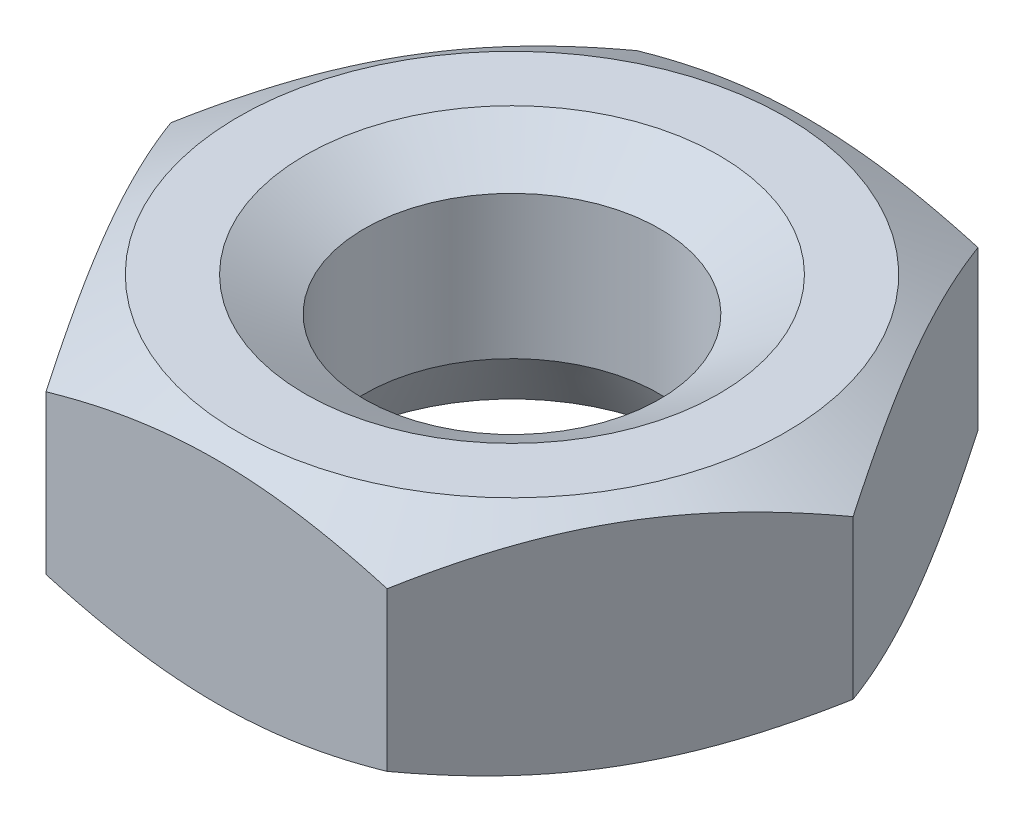
from build123d import *

# Parameters (mm, degrees)
SKETCH_1_R             = 2.5
EXTRUDE_1_DEPTH        = 4
CHAMFER_1_SIZE         = 1
CHAMFER_1_SIZE2        = 0.577350269
CHAMFER_1_PART_2_SIZE  = 1
CHAMFER_1_PART_2_SIZE2 = 0.577350269


with BuildPart() as part:
    # Эскиз1 → Бобышка-Вытянуть1 (new body)
    with BuildSketch(Plane(origin=(0, 0, 0), x_dir=(1, 0, 0), z_dir=(0, 1, 0))):
        Polygon((-5.773502692, 0), (-2.886751346, -5), (2.886751346, -5), (5.773502692, 0), (2.886751346, 5), (-2.886751346, 5), align=None)
        Circle(SKETCH_1_R, mode=Mode.SUBTRACT)
    extrude(amount=EXTRUDE_1_DEPTH)

    # Фаска1
    chamfer_1_edges = [part.edges().sort_by_distance(p)[0] for p in [
        (-2.5, 0, 0),
    ]]
    chamfer_1_side = [part.faces().sort_by_distance(p)[0] for p in [
        (-2.5, 2, 0),
    ]]
    chamfer(chamfer_1_edges, length=CHAMFER_1_SIZE, length2=CHAMFER_1_SIZE2, reference=chamfer_1_side[0])

    # Фаска1 part 2
    chamfer_1_part_2_edges = [part.edges().sort_by_distance(p)[0] for p in [
        (-2.5, 4, 0),
    ]]
    chamfer_1_part_2_side = [part.faces().sort_by_distance(p)[0] for p in [
        (-4.197839453, 4, 2.423623738),
    ]]
    chamfer(chamfer_1_part_2_edges, length=CHAMFER_1_PART_2_SIZE, length2=CHAMFER_1_PART_2_SIZE2, reference=chamfer_1_part_2_side[0])

    # Эскиз2 → Вырез-Повернуть1 (revolve, cut)
    with BuildSketch(Plane(origin=(0, 0, 0), x_dir=(0, 0, -1), z_dir=(1, 0, 0))):
        Polygon((4.62815384, 0), (6.62815384, 0), (6.62815384, 1.154700538), align=None)
        Polygon((4.62815384, 4), (6.62815384, 2.845299462), (6.62815384, 4), align=None)
    revolve(axis=Axis((0, 0, 0), (0, 1, 0)), mode=Mode.SUBTRACT)


solid = part.part
